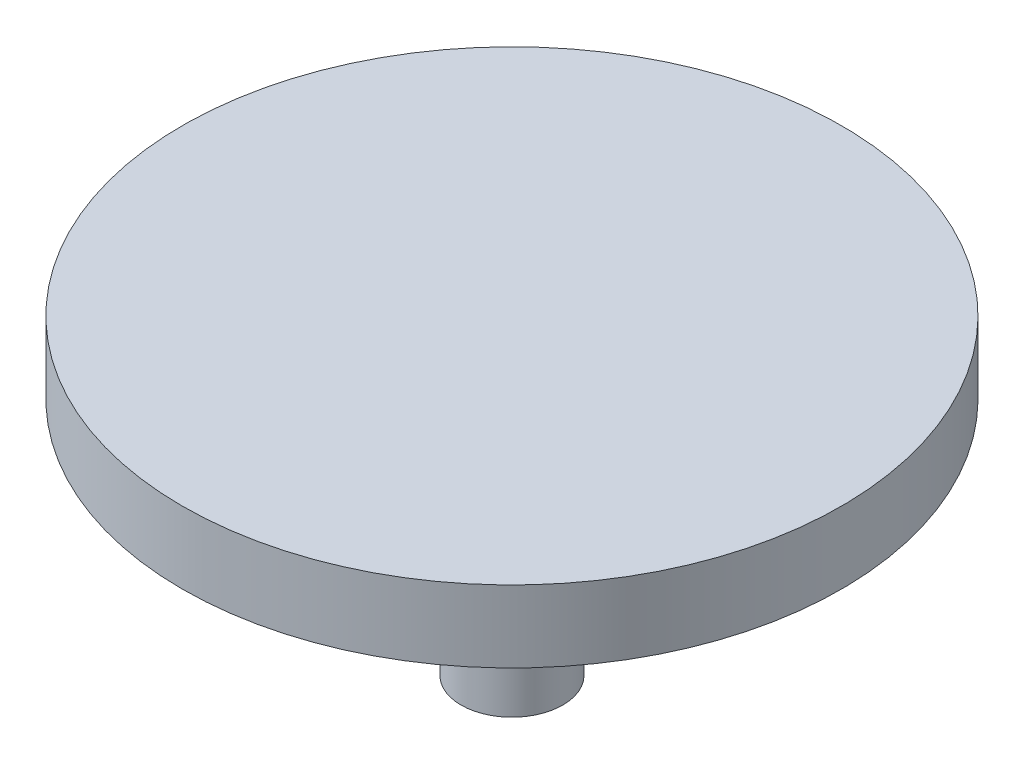
from build123d import *

# Parameters (mm, degrees)
ESBO_O1_R                = 4.25
RESSALTO_EXTRUS_O1_DEPTH = 20
ESBO_O2_R                = 27.5
RESSALTO_EXTRUS_O2_DEPTH = 6


with BuildPart() as part:
    # Esboço1 → Ressalto-extrusão1 (new body)
    with BuildSketch(Plane(origin=(0, 0, 0), x_dir=(1, 0, 0), z_dir=(0, 1, 0))):
        Circle(ESBO_O1_R)
    extrude(amount=RESSALTO_EXTRUS_O1_DEPTH)

    # Esboço2 → Ressalto-extrusão2 (add)
    with BuildSketch(Plane(origin=(0, 20, 0), x_dir=(1, 0, 0), z_dir=(0, 1, 0))):
        Circle(ESBO_O2_R)
    extrude(amount=RESSALTO_EXTRUS_O2_DEPTH)


solid = part.part
